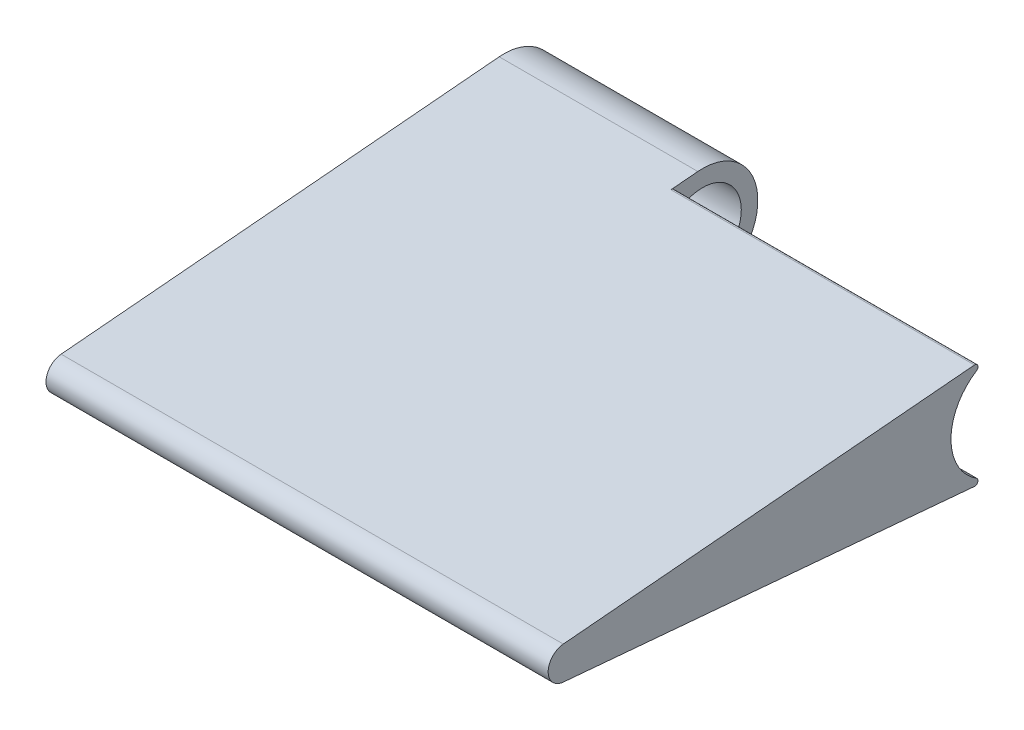
from build123d import *

# Parameters (mm, degrees)
BOSS_EXTRUDE1_DEPTH = 27.5
BOSS_EXTRUDE2_START = -18
SKETCH1_3_R         = 3.5
BOSS_EXTRUDE2_DEPTH = 18
FILLET1_R           = 0.3
CUT_EXTRUDE1_START  = 6
SKETCH2_W           = 18
SKETCH2_H           = 4.33028374
CUT_EXTRUDE1_DEPTH  = 48


with BuildPart() as part:
    # Sketch1 → Boss-Extrude1 (new body)
    with BuildSketch(Plane(origin=(0, 0, 0), x_dir=(0, 0, -1), z_dir=(1, 0, 0))):
        with BuildLine():
            Line((-0.4375, 4.980822598), (-40.13125, 1.494246779))
            ThreePointArc((-40.13125, 1.494246779), (-41.5, 0), (-40.13125, -1.494246779))
            Line((-40.13125, -1.494246779), (-0.4375, -4.980822598))
            ThreePointArc((-0.4375, -4.980822598), (-5, 0), (-0.4375, 4.980822598))
        make_face()
    extrude(amount=BOSS_EXTRUDE1_DEPTH)

    # Sketch1_3 → Boss-Extrude2 (add)
    with BuildSketch(Plane(origin=(0, 0, 0), x_dir=(0, 0, -1), z_dir=(1, 0, 0)).offset(BOSS_EXTRUDE2_START)):
        with BuildLine():
            Line((-0.4375, 4.980822598), (-40.13125, 1.494246779))
            ThreePointArc((-40.13125, 1.494246779), (-41.5, 0), (-40.13125, -1.494246779))
            Line((-40.13125, -1.494246779), (-0.4375, -4.980822598))
            ThreePointArc((-0.4375, -4.980822598), (5, 0), (-0.4375, 4.980822598))
        make_face()
        Circle(SKETCH1_3_R, mode=Mode.SUBTRACT)
    extrude(amount=BOSS_EXTRUDE2_DEPTH)

    # Fillet1
    fillet1_edges = [part.edges().sort_by_distance(p)[0] for p in [
        (13.75, -4.980822598, 0.4375),
        (13.75, 4.980822598, 0.4375),
    ]]
    fillet(fillet1_edges, radius=FILLET1_R)

    # Sketch2 → Cut-Extrude1 (cut)
    with BuildSketch(Plane.XY.offset(CUT_EXTRUDE1_START)):
        with Locations((-9, -3.96514187)):
            Rectangle(SKETCH2_W, SKETCH2_H)
    extrude(amount=CUT_EXTRUDE1_DEPTH, mode=Mode.SUBTRACT)


solid = part.part
